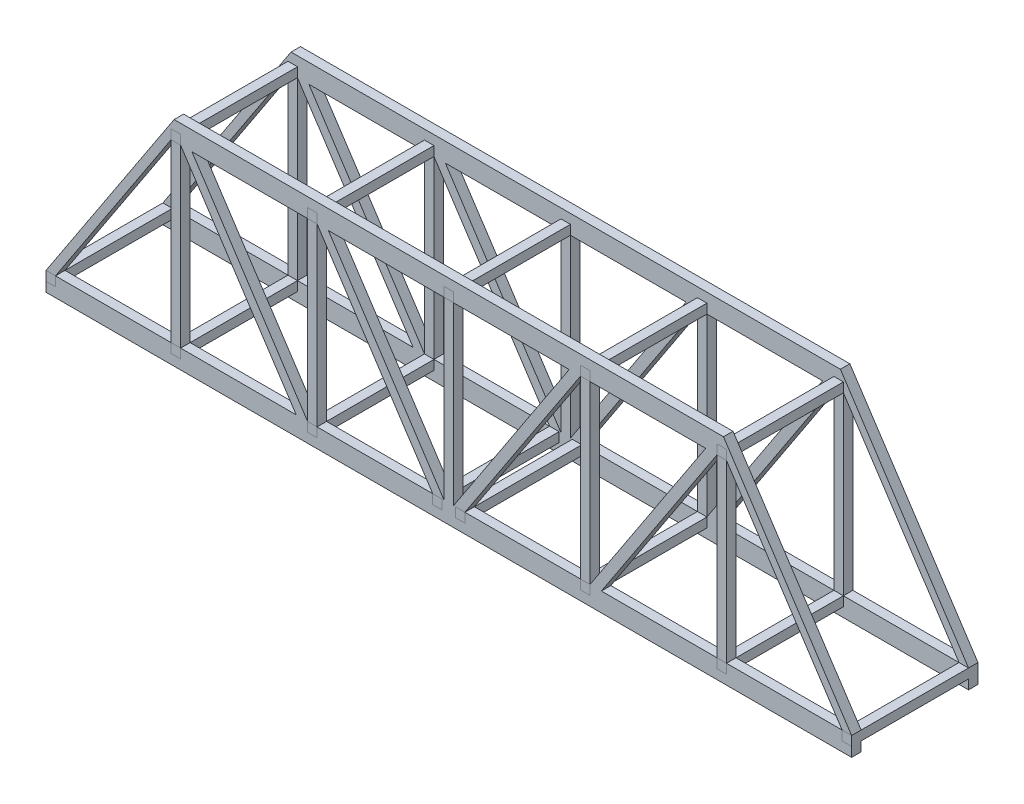
from build123d import *

# Parameters (mm, degrees)
BOSS_EXTRUDE1_DEPTH      = 6
SKETCH2_W                = 6
SKETCH2_H                = 6
BOSS_EXTRUDE2_DEPTH      = 0.0001
BOSS_EXTRUDE2_DEPTH_BACK = 40


with BuildPart() as part:
    # Sketch1 → Boss-Extrude1 (new body)
    with BuildSketch(Plane.XY):
        Polygon((-30.810486932, 6), (-30.810486932, 0), (479.189513068, 0), (479.189513068, 6), (479.189513068, 12), (398.082139827, 135.244350991), (50.29688631, 135.244350991), (-30.810486932, 12), align=None)
        Polygon((221.189513068, 12), (221.189513068, 123.246431283), (147.977996668, 123.246431283), align=None, mode=Mode.SUBTRACT)
        Polygon((54.401029468, 12), (54.401029468, 123.246431283), (127.612545868, 12), align=None, mode=Mode.SUBTRACT)
        Polygon((134.795271268, 12), (61.583754868, 123.246431283), (134.795271268, 123.246431283), align=None, mode=Mode.SUBTRACT)
        Polygon((140.795271268, 12), (140.795271268, 123.246431283), (214.006787668, 12), align=None, mode=Mode.SUBTRACT)
        Polygon((-24.810486932, 12), (48.401029468, 123.246431283), (48.401029468, 12), align=None, mode=Mode.SUBTRACT)
        Polygon((307.583754868, 12), (234.372238468, 12), (307.583754868, 123.246431283), align=None, mode=Mode.SUBTRACT)
        Polygon((399.977996668, 12), (473.189513068, 12), (399.977996668, 123.246431283), align=None, mode=Mode.SUBTRACT)
        Polygon((393.977996668, 12), (320.766480268, 12), (393.977996668, 123.246431283), align=None, mode=Mode.SUBTRACT)
        Polygon((300.401029468, 123.246431283), (227.189513068, 123.246431283), (227.189513068, 12), align=None, mode=Mode.SUBTRACT)
        Polygon((313.583754868, 123.246431283), (313.583754868, 12), (386.795271268, 123.246431283), align=None, mode=Mode.SUBTRACT)
    extrude(amount=BOSS_EXTRUDE1_DEPTH)

    # Sketch2 → Boss-Extrude2 (add, two sides)
    with BuildSketch(Plane(origin=(0, 0, 0), x_dir=(-1, 0, 0), z_dir=(0, 0, -1))) as boss_extrude2_sk:
        with Locations((-476.189513068, 9)):
            Rectangle(SKETCH2_W, SKETCH2_H)
        with Locations((-396.977996668, 9)):
            Rectangle(SKETCH2_W, SKETCH2_H)
        with Locations((-310.583754868, 9)):
            Rectangle(SKETCH2_W, SKETCH2_H)
        with Locations((-231.372238468, 9)):
            Rectangle(SKETCH2_W, SKETCH2_H)
        with Locations((-396.977996668, 126.246431283)):
            Rectangle(SKETCH2_W, SKETCH2_H)
        with Locations((-310.583754868, 126.246431283)):
            Rectangle(SKETCH2_W, SKETCH2_H)
        with Locations((-137.795271268, 126.246431283)):
            Rectangle(SKETCH2_W, SKETCH2_H)
        with Locations((-51.401029468, 126.246431283)):
            Rectangle(SKETCH2_W, SKETCH2_H)
        with Locations((-217.006787668, 9)):
            Rectangle(SKETCH2_W, SKETCH2_H)
        with Locations((-137.795271268, 9)):
            Rectangle(SKETCH2_W, SKETCH2_H)
        with Locations((-51.401029468, 9)):
            Rectangle(SKETCH2_W, SKETCH2_H)
        with Locations((27.810486932, 9)):
            Rectangle(SKETCH2_W, SKETCH2_H)
        with Locations((-224.189513068, 126.246431283)):
            Rectangle(SKETCH2_W, SKETCH2_H)
    extrude(amount=BOSS_EXTRUDE2_DEPTH)
    extrude(boss_extrude2_sk.sketch, amount=-BOSS_EXTRUDE2_DEPTH_BACK)

    # Mirror1: part across plane


with BuildPart() as part_1:
    add(part.part)
    add(part.part.mirror(Plane.XY.offset(40)))


solid = part_1.part
